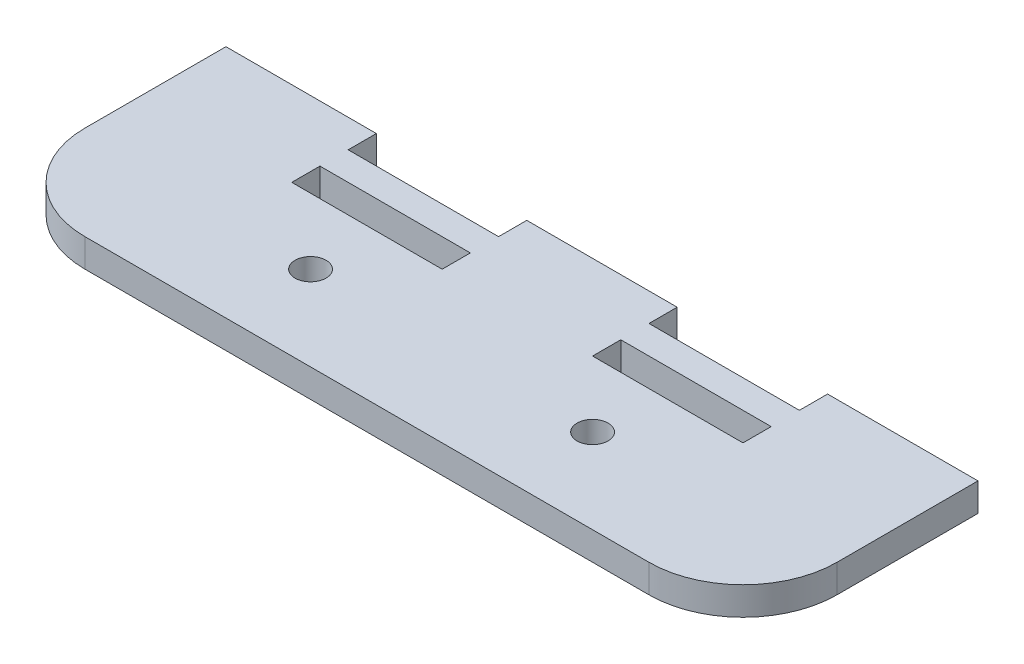
from build123d import *

# Parameters (mm, degrees)
SKETCH1_R           = 1.65
SKETCH1_W           = 16
SKETCH1_H           = 3
BOSS_EXTRUDE1_DEPTH = 3


with BuildPart() as part:
    # Sketch1 → Boss-Extrude1 (new body)
    with BuildSketch(Plane(origin=(0, 0, 0), x_dir=(1, 0, 0), z_dir=(0, 1, 0))):
        with BuildLine():
            Line((30, -12.5), (-30, -12.5))
            ThreePointArc((-30, -12.5), (-37.071067812, -9.571067812), (-40, -2.5))
            Line((-40, -2.5), (-40, 12.5))
            Line((-40, 12.5), (-24, 12.5))
            Line((-24, 12.5), (-24, 9.5))
            Line((-24, 9.5), (-8, 9.5))
            Line((-8, 9.5), (-8, 12.5))
            Line((-8, 12.5), (8, 12.5))
            Line((8, 12.5), (8, 9.5))
            Line((8, 9.5), (24, 9.5))
            Line((24, 9.5), (24, 12.5))
            Line((24, 12.5), (40, 12.5))
            Line((40, 12.5), (40, -2.5))
            ThreePointArc((40, -2.5), (37.071067812, -9.571067812), (30, -12.5))
        make_face()
        with Locations((-15, -3.5)):
            Circle(SKETCH1_R, mode=Mode.SUBTRACT)
        with Locations((15, -3.5)):
            Circle(SKETCH1_R, mode=Mode.SUBTRACT)
        with Locations((-16, 5)):
            Rectangle(SKETCH1_W, SKETCH1_H, mode=Mode.SUBTRACT)
        with Locations((16, 5)):
            Rectangle(SKETCH1_W, SKETCH1_H, mode=Mode.SUBTRACT)
    extrude(amount=BOSS_EXTRUDE1_DEPTH)


solid = part.part
